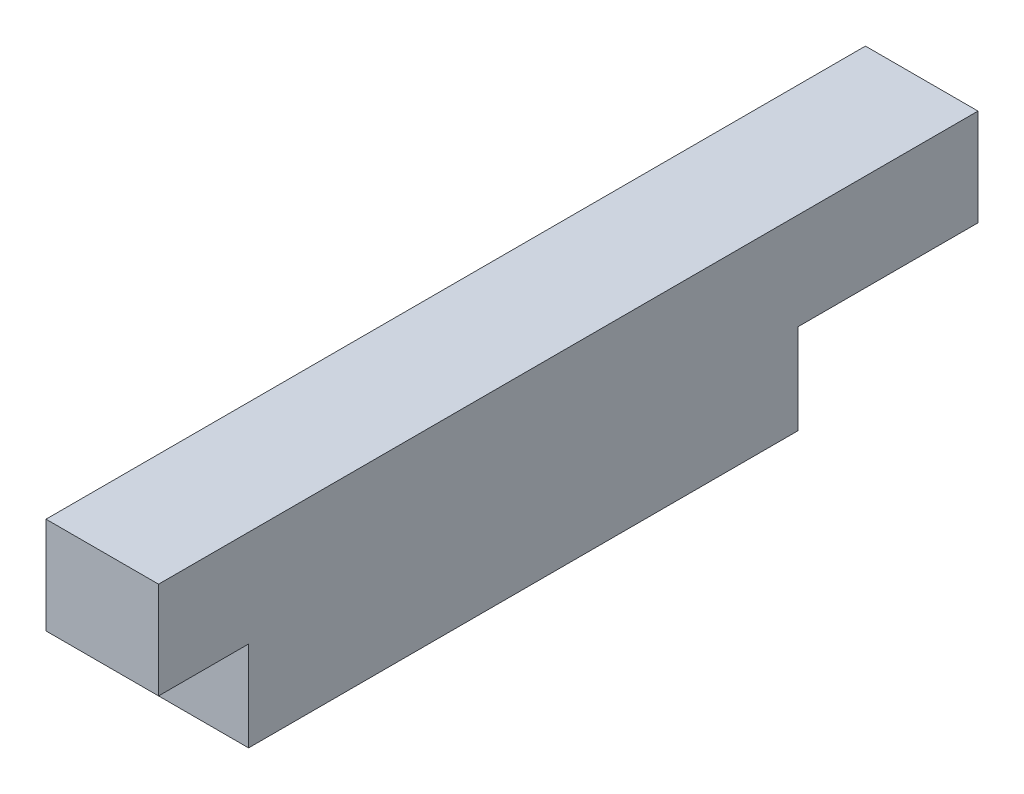
from build123d import *

# Parameters (mm, degrees)
BOSS_EXTRUDE1_DEPTH             = 5
TAP_DRILL_FOR_M2X0_4_TAP1_D     = 1.6
TAP_DRILL_FOR_M2X0_4_TAP1_DEPTH = 5


with BuildPart() as part:
    # Sketch1 → Boss-Extrude1 (new body)
    with BuildSketch(Plane(origin=(0, 0, 0), x_dir=(0, 0, -1), z_dir=(1, 0, 0))):
        Polygon((0, 4), (0, 8.3), (36.4, 8.3), (36.4, 4), (28.4, 4), (28.4, 0), (4, 0), (4, 4), align=None)
    extrude(amount=BOSS_EXTRUDE1_DEPTH)

    # Tap Drill for M2x0.4 Tap1
    with Locations(Plane(origin=(0, 0, 0), x_dir=(-1, 0, 0), z_dir=(0, -1, 0))):
        with Locations((-2.5, 9), (-2.5, 23.4)):
            Hole(TAP_DRILL_FOR_M2X0_4_TAP1_D / 2, depth=TAP_DRILL_FOR_M2X0_4_TAP1_DEPTH)


solid = part.part
